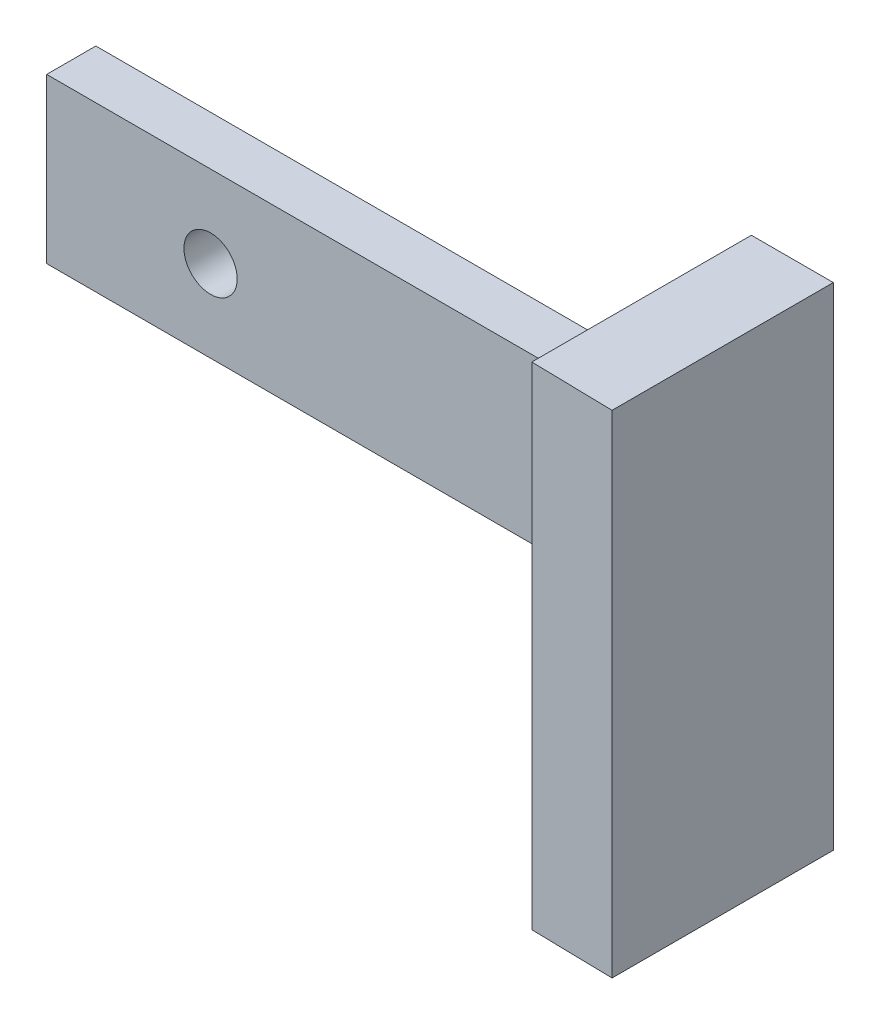
from build123d import *

# Parameters (mm, degrees)
ESQUISSE1_W             = 45
ESQUISSE1_H             = 10
BOSS_EXTRU_1_DEPTH      = 3
ESQUISSE2_R             = 1.625
ENL_V_MAT_EXTRU_1_DEPTH = 4
ESQUISSE3_W             = 5
ESQUISSE3_H             = 3
BOSS_EXTRU_2_DEPTH      = 10
BOSS_EXTRU_2_DEPTH_BACK = 20
ESQUISSE4_W             = 5
ESQUISSE4_H             = 30
BOSS_EXTRU_3_DEPTH      = 10.5
ENL_V_MAT_EXTRU_2_DEPTH = 31


with BuildPart() as part:
    # Esquisse1 → Boss.-Extru.1 (new body)
    with BuildSketch(Plane.XY):
        with Locations((17.5, -5)):
            Rectangle(ESQUISSE1_W, ESQUISSE1_H)
    extrude(amount=BOSS_EXTRU_1_DEPTH)

    # Esquisse2 → Enlèv. mat.-Extru.1 (cut, through all)
    with BuildSketch(Plane.XY.offset(3)):
        with Locations((30, -5)):
            Circle(ESQUISSE2_R)
        with Locations((5, -5)):
            Circle(ESQUISSE2_R)
    extrude(amount=-ENL_V_MAT_EXTRU_1_DEPTH, mode=Mode.SUBTRACT)

    # Esquisse3 → Boss.-Extru.2 (add, two sides)
    with BuildSketch(Plane.XZ.offset(10)) as boss_extru_2_sk:
        with Locations((37.5, 1.5)):
            Rectangle(ESQUISSE3_W, ESQUISSE3_H)
    extrude(amount=BOSS_EXTRU_2_DEPTH)
    extrude(boss_extru_2_sk.sketch, amount=-BOSS_EXTRU_2_DEPTH_BACK)

    # Esquisse4 → Boss.-Extru.3 (add)
    with BuildSketch(Plane.XY.offset(3)):
        with Locations((37.5, -5)):
            Rectangle(ESQUISSE4_W, ESQUISSE4_H)
    extrude(amount=BOSS_EXTRU_3_DEPTH)

    # Esquisse5 → Enlèv. mat.-Extru.2 (cut, through all)
    with BuildSketch(Plane.XZ.offset(20)):
        Polygon((35, 13.5), (40, 13.5), (35, 13.4), align=None)
    extrude(amount=-ENL_V_MAT_EXTRU_2_DEPTH, mode=Mode.SUBTRACT)


solid = part.part
